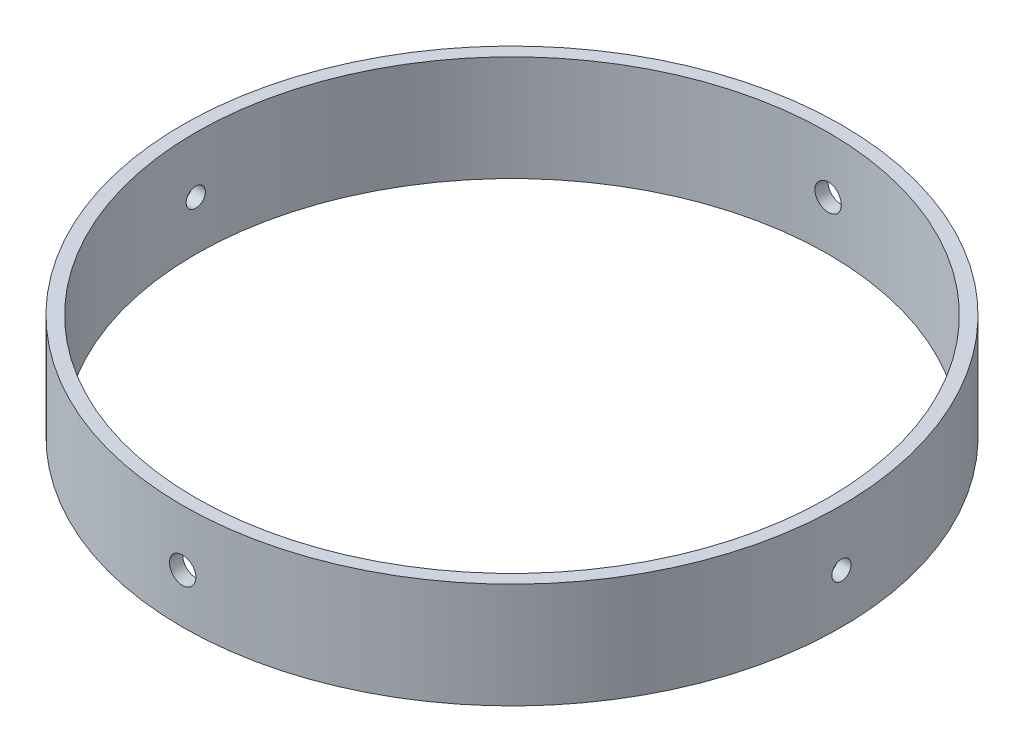
from build123d import *

# Parameters (mm, degrees)
SKETCH1_R               = 79.375
SKETCH1_R_2             = 76.2
BOSS_EXTRUDE1_DEPTH     = 25.4
CUT_EXTRUDE4_REACH      = 181.296
SKETCH2_R               = 2.3114
CIRPATTERN1_COUNT       = 4
CUT_EXTRUDE6_DEPTH      = 180.296160538
CUT_EXTRUDE6_DEPTH_BACK = 180.296160538
SKETCH4_R               = 3.175


with BuildPart() as part:
    # Sketch1 → Boss-Extrude1 (new body)
    with BuildSketch(Plane(origin=(0, 0, 0), x_dir=(1, 0, 0), z_dir=(0, 1, 0))):
        Circle(SKETCH1_R)
        Circle(SKETCH1_R_2, mode=Mode.SUBTRACT)
    extrude(amount=BOSS_EXTRUDE1_DEPTH)

    # Sketch2 → Cut-Extrude4 (cut, up to next)
    with BuildSketch(Plane.XY.offset(79.375), mode=Mode.PRIVATE) as cut_extrude4_sk1:
        with Locations((0, 11.890925676)):
            Circle(SKETCH2_R)
    cut_extrude4_tool1 = extrude(cut_extrude4_sk1.sketch, amount=-CUT_EXTRUDE4_REACH, mode=Mode.PRIVATE) & part.part
    cut_extrude4 = cut_extrude4_tool1.solids().sort_by_distance((0, 11.890926, 79.375))[0]
    add(cut_extrude4, mode=Mode.SUBTRACT)

    # CirPattern1: Cut-Extrude4 ×4 about axis
    cirpattern1_axis = Axis((0, 25.4, 0), (0, -1, 0))
    for i in range(1, CIRPATTERN1_COUNT):
        add(cut_extrude4.rotate(cirpattern1_axis, i * 360 / CIRPATTERN1_COUNT), mode=Mode.SUBTRACT)

    # Sketch4 → Cut-Extrude6 (cut, two sides: drawn at the far end of the back side and taken through both)
    with BuildSketch(Plane.XY.offset(79.375).offset(-CUT_EXTRUDE6_DEPTH_BACK)):
        with Locations((0, 11.890925676)):
            Circle(SKETCH4_R)
    extrude(amount=CUT_EXTRUDE6_DEPTH + CUT_EXTRUDE6_DEPTH_BACK, mode=Mode.SUBTRACT)


solid = part.part
